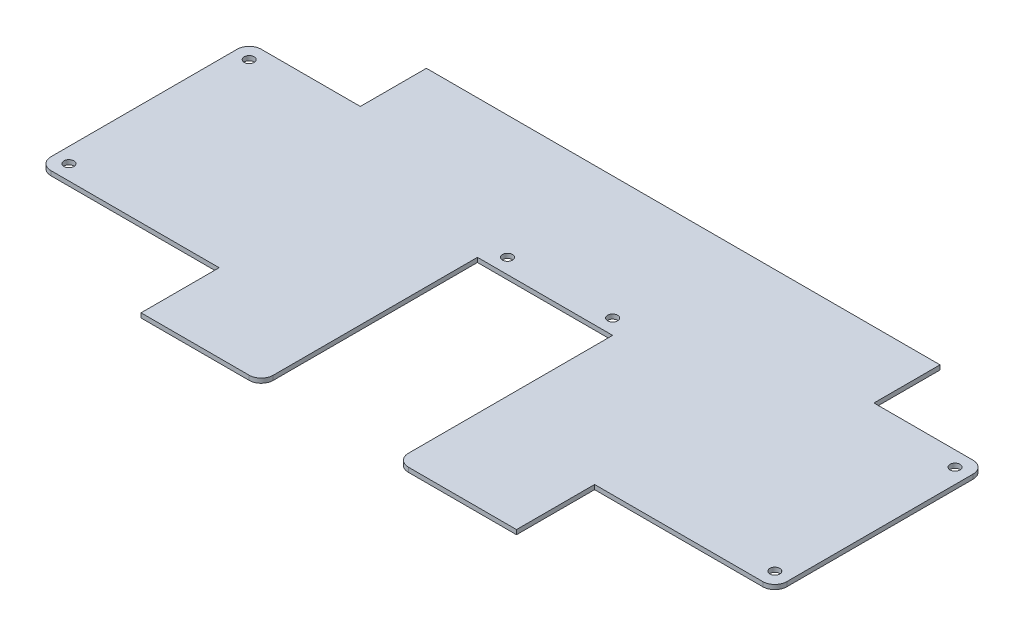
from build123d import *

# Parameters (mm, degrees)
SKETCH1_W           = 245
SKETCH1_H           = 118
BOSS_EXTRUDE1_DEPTH = 1.5
SKETCH2_W           = 37
SKETCH2_H           = 22
SKETCH2_W_2         = 60
SKETCH2_H_2         = 26
SKETCH2_W_3         = 45
SKETCH2_H_3         = 72
CUT_EXTRUDE1_DEPTH  = 2.5
SKETCH3_R           = 1.65
CUT_EXTRUDE2_DEPTH  = 10
FILLET1_R           = 4


with BuildPart() as part:
    # Sketch1 → Boss-Extrude1 (new body)
    with BuildSketch(Plane(origin=(0, 0, 0), x_dir=(1, 0, 0), z_dir=(0, 1, 0))):
        with Locations((122.5, 59)):
            Rectangle(SKETCH1_W, SKETCH1_H)
    extrude(amount=BOSS_EXTRUDE1_DEPTH)

    # Sketch2 → Cut-Extrude1 (cut, through all)
    with BuildSketch(Plane(origin=(0, 1.5, 0), x_dir=(1, 0, 0), z_dir=(0, 1, 0))):
        with Locations((18.5, 107)):
            Rectangle(SKETCH2_W, SKETCH2_H)
        with Locations((30, 13)):
            Rectangle(SKETCH2_W_2, SKETCH2_H_2)
        with Locations((226.5, 107)):
            Rectangle(SKETCH2_W, SKETCH2_H)
        with Locations((215, 13)):
            Rectangle(SKETCH2_W_2, SKETCH2_H_2)
        with Locations((122.5, 36)):
            Rectangle(SKETCH2_W_3, SKETCH2_H_3)
    extrude(amount=-CUT_EXTRUDE1_DEPTH, mode=Mode.SUBTRACT)

    # Sketch3 → Cut-Extrude2 (cut)
    with BuildSketch(Plane.XZ):
        with Locations((5, -31)):
            Circle(SKETCH3_R)
        with Locations((5, -91)):
            Circle(SKETCH3_R)
        with Locations((240, -31)):
            Circle(SKETCH3_R)
        with Locations((240, -91)):
            Circle(SKETCH3_R)
        with Locations((105, -77)):
            Circle(SKETCH3_R)
        with Locations((140, -77)):
            Circle(SKETCH3_R)
    extrude(amount=-CUT_EXTRUDE2_DEPTH, mode=Mode.SUBTRACT)

    # Fillet1
    fillet1_edges = [part.edges().sort_by_distance(p)[0] for p in [
        (0, 0.75, -26),
        (245, 0.75, -96),
        (245, 0.75, -26),
        (100, 0.75, 0),
        (145, 0.75, 0),
        (0, 0.75, -96),
    ]]
    fillet(fillet1_edges, radius=FILLET1_R)


solid = part.part
